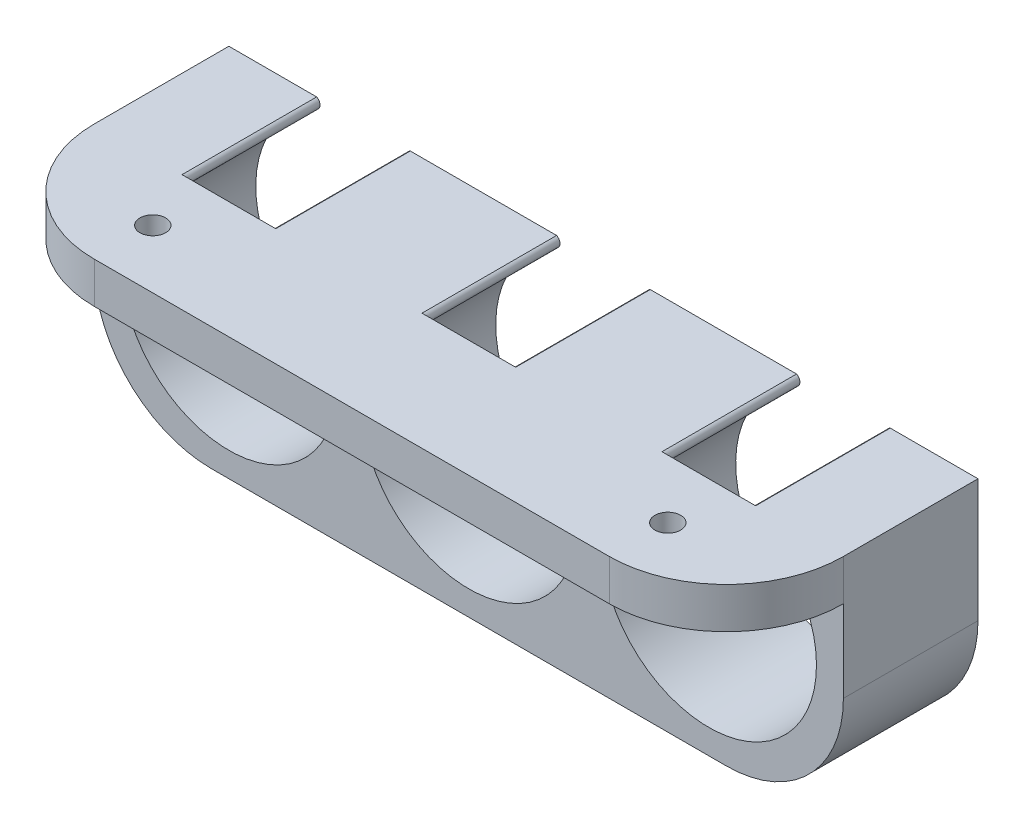
from build123d import *

# Parameters (mm, degrees)
BOSS_EXTRU_2_DEPTH      = 11.5
ESQUISSE2_W             = 64
ESQUISSE2_H             = 3.5
BOSS_EXTRU_3_DEPTH      = 10
CONG_1_R                = 10
ESQUISSE3_R             = 1.1
ENL_V_MAT_EXTRU_1_DEPTH = 4.5
ENL_V_MAT_EXTRU_2_DEPTH = 1.4


with BuildPart() as part:
    # Esquisse1 → Boss.-Extru.2 (new body)
    with BuildSketch(Plane.XY):
        with BuildLine():
            Line((-32, 10.25), (-24.5, 10.25))
            ThreePointArc((-24.5, 10.25), (-24.212828793, 9.792463035), (-24.5, 9.334926071))
            ThreePointArc((-24.5, 9.334926071), (-20.5, -8.15), (-16.5, 9.334926071))
            ThreePointArc((-16.5, 9.334926071), (-16.787171207, 9.792463035), (-16.5, 10.25))
            Line((-16.5, 10.25), (-4, 10.25))
            ThreePointArc((-4, 10.25), (-3.712828793, 9.792463035), (-4, 9.334926071))
            ThreePointArc((-4, 9.334926071), (0, -8.15), (4, 9.334926071))
            ThreePointArc((4, 9.334926071), (3.712828793, 9.792463035), (4, 10.25))
            Line((4, 10.25), (16.5, 10.25))
            ThreePointArc((16.5, 10.25), (16.787171207, 9.792463035), (16.5, 9.334926071))
            ThreePointArc((16.5, 9.334926071), (20.5, -8.15), (24.5, 9.334926071))
            ThreePointArc((24.5, 9.334926071), (24.212828793, 9.792463035), (24.5, 10.25))
            Line((24.5, 10.25), (32, 10.25))
            Line((32, 10.25), (32, -0.25))
            ThreePointArc((32, -0.25), (29.071067812, -7.321067812), (22, -10.25))
            Line((22, -10.25), (-22, -10.25))
            ThreePointArc((-22, -10.25), (-29.071067812, -7.321067812), (-32, -0.25))
            Line((-32, -0.25), (-32, 10.25))
        make_face()
    extrude(amount=BOSS_EXTRU_2_DEPTH)

    # Esquisse2 → Boss.-Extru.3 (add)
    with BuildSketch(Plane.XY.offset(11.5)):
        with Locations((0, 8.5)):
            Rectangle(ESQUISSE2_W, ESQUISSE2_H)
    extrude(amount=BOSS_EXTRU_3_DEPTH)

    # Congé1
    cong_1_edges = [part.edges().sort_by_distance(p)[0] for p in [
        (32, 8.5, 21.5),
        (-32, 8.5, 21.5),
    ]]
    fillet(cong_1_edges, radius=CONG_1_R)

    # Esquisse3 → Enlèv. mat.-Extru.1 (cut, through all)
    with BuildSketch(Plane.XZ.offset(-6.75)):
        with Locations((-22, 16.5)):
            Circle(ESQUISSE3_R)
        with Locations((22, 16.5)):
            Circle(ESQUISSE3_R)
    extrude(amount=-ENL_V_MAT_EXTRU_1_DEPTH, mode=Mode.SUBTRACT)

    # Esquisse4 → Enlèv. mat.-Extru.2 (cut)
    with BuildSketch(Plane.XZ.offset(-6.75)):
        Polygon((-20.845299462, 14.5), (-19.690598923, 16.5), (-20.845299462, 18.5), (-23.154700538, 18.5), (-24.309401077, 16.5), (-23.154700538, 14.5), align=None)
        Polygon((24.309401077, 16.5), (23.154700538, 18.5), (20.845299462, 18.5), (19.690598923, 16.5), (20.845299462, 14.5), (23.154700538, 14.5), align=None)
    extrude(amount=-ENL_V_MAT_EXTRU_2_DEPTH, mode=Mode.SUBTRACT)


solid = part.part
